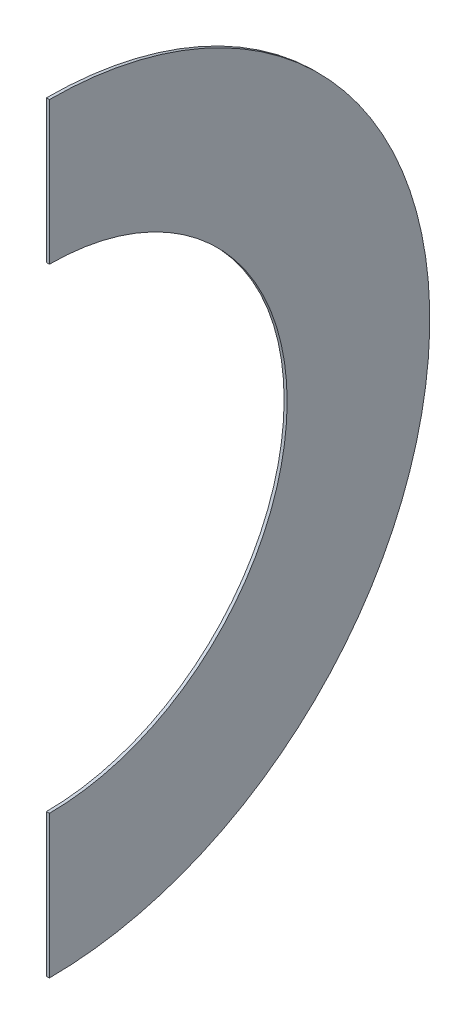
from build123d import *

# Parameters (mm, degrees)
BOSS_EXTRUDE1_DEPTH = 1.5875


with BuildPart() as part:
    # Sketch1 → Boss-Extrude1 (new body)
    with BuildSketch(Plane(origin=(0, 0, 0), x_dir=(0, 0, -1), z_dir=(1, 0, 0))):
        with BuildLine():
            ThreePointArc((200, 0), (141.421356237, 141.421356237), (0, 200))
            Line((0, 200), (0, 125))
            ThreePointArc((0, 125), (88.388347648, 88.388347648), (125, 0))
            ThreePointArc((125, 0), (88.388347648, -88.388347648), (0, -125))
            Line((0, -125), (0, -200))
            ThreePointArc((0, -200), (141.421356237, -141.421356237), (200, 0))
        make_face()
    extrude(amount=BOSS_EXTRUDE1_DEPTH)


solid = part.part
